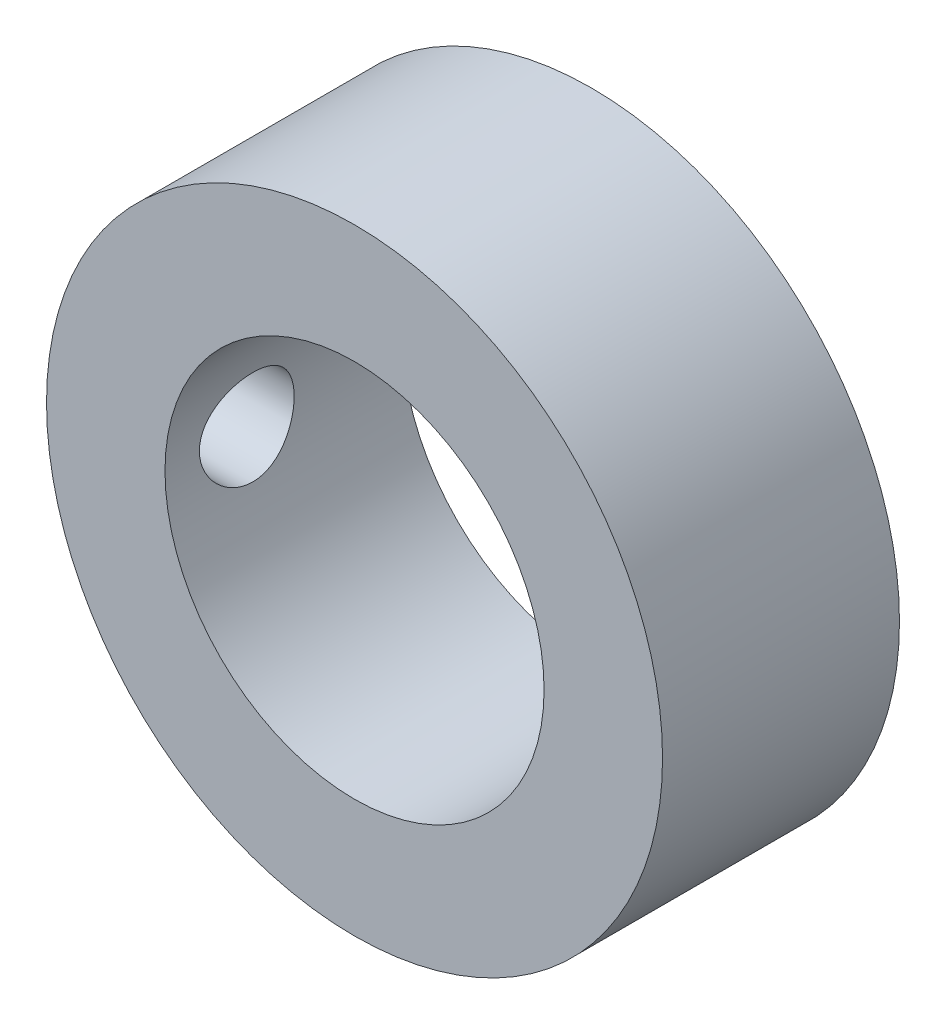
from build123d import *

# Parameters (mm, degrees)
ESQUISSE1_R      = 6.5
ESQUISSE1_R_2    = 4
EXTRUSION1_DEPTH = 5
ESQUISSE2_R      = 1
EXTRUSION2_DEPTH = 7.5


with BuildPart() as part:
    # Esquisse1 → Extrusion1 (new body)
    with BuildSketch(Plane.XY):
        Circle(ESQUISSE1_R)
        Circle(ESQUISSE1_R_2, mode=Mode.SUBTRACT)
    extrude(amount=EXTRUSION1_DEPTH)

    # Esquisse2 → Extrusion2 (cut, through all)
    with BuildSketch(Plane(origin=(0, 0, 0), x_dir=(0, 0, -1), z_dir=(1, 0, 0))):
        with Locations((-3.274512487, 0)):
            Circle(ESQUISSE2_R)
    extrude(amount=-EXTRUSION2_DEPTH, mode=Mode.SUBTRACT)


solid = part.part
